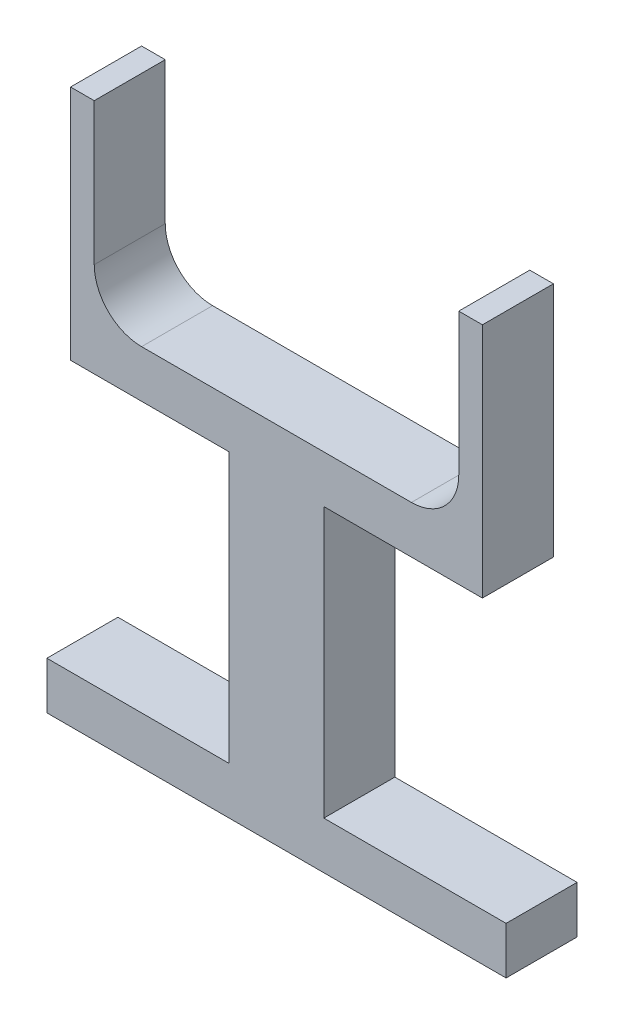
from build123d import *

# Parameters (mm, degrees)
SKETCH_1_W      = 5
SKETCH_1_H      = 40
SKETCH_1_W_2    = 20
SKETCH_1_H_2    = 57
SKETCH_1_W_3    = 97
SKETCH_1_H_3    = 10
EXTRUDE_1_DEPTH = 15
FILLET_1_R      = 10


with BuildPart() as part:
    # 草圖1 → 填料-伸長1 (new body)
    with BuildSketch(Plane.XY):
        with Locations((-69.872316496, 75.770491803)):
            Rectangle(SKETCH_1_W, SKETCH_1_H)
        Polygon((-72.372316496, 45.770491803), (-38.872316496, 45.770491803), (-18.872316496, 45.770491803), (14.627683504, 45.770491803), (14.627683504, 55.770491803), (9.627683504, 55.770491803), (-67.372316496, 55.770491803), (-72.372316496, 55.770491803), align=None)
        with Locations((12.127683504, 75.770491803)):
            Rectangle(SKETCH_1_W, SKETCH_1_H)
        with Locations((-28.872316496, 17.270491803)):
            Rectangle(SKETCH_1_W_2, SKETCH_1_H_2)
        with Locations((-28.872316496, -16.229508197)):
            Rectangle(SKETCH_1_W_3, SKETCH_1_H_3)
    extrude(amount=EXTRUDE_1_DEPTH)

    # 圓角1
    fillet_1_edges = [part.edges().sort_by_distance(p)[0] for p in [
        (-67.372316496, 55.770491803, 7.5),
        (9.627683504, 55.770491803, 7.5),
    ]]
    fillet(fillet_1_edges, radius=FILLET_1_R)


solid = part.part
